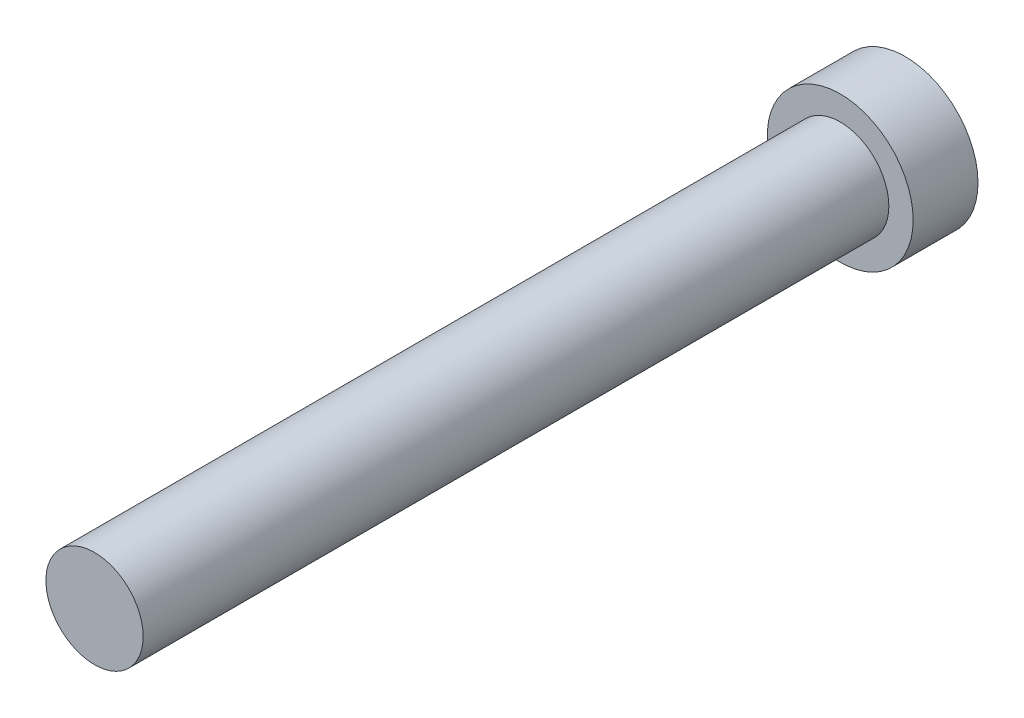
from build123d import *

# Parameters (mm, degrees)
SKETCH1_R           = 22.5
BOSS_EXTRUDE1_DEPTH = 20
SKETCH2_R           = 15
BOSS_EXTRUDE2_DEPTH = 230


with BuildPart() as part:
    # Sketch1 → Boss-Extrude1 (new body)
    with BuildSketch(Plane.XY):
        Circle(SKETCH1_R)
    extrude(amount=BOSS_EXTRUDE1_DEPTH)

    # Sketch2 → Boss-Extrude2 (add)
    with BuildSketch(Plane.XY.offset(20)):
        Circle(SKETCH2_R)
    extrude(amount=BOSS_EXTRUDE2_DEPTH)


solid = part.part
